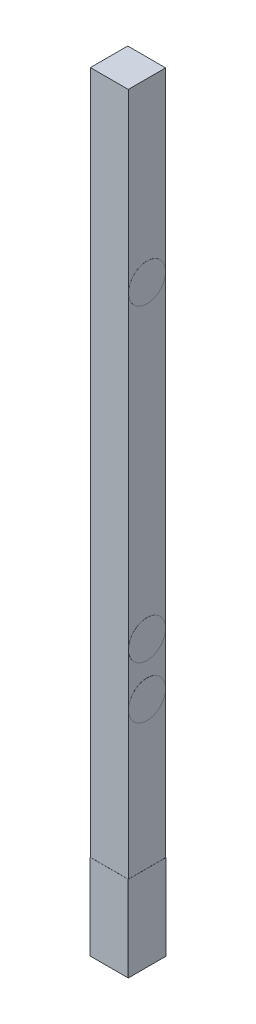
from build123d import *

# Parameters (mm, degrees)
SKETCH1_W           = 45.02
SKETCH1_H           = 44.376857142
BOSS_EXTRUDE1_DEPTH = 914.4
SKETCH2_R           = 22
BOSS_EXTRUDE2_DEPTH = 0.1
SKETCH3_W           = 44.376857142
SKETCH3_H           = 101.6
BOSS_EXTRUDE3_DEPTH = 0.1
SKETCH4_W           = 45.12
SKETCH4_H           = 101.6
BOSS_EXTRUDE4_DEPTH = 0.1
SKETCH5_W           = 44.476857142
SKETCH5_H           = 101.6
BOSS_EXTRUDE5_DEPTH = 0.1
SKETCH6_W           = 45.12
SKETCH6_H           = 101.6
BOSS_EXTRUDE6_DEPTH = 0.1


with BuildPart() as part:
    # Sketch1 → Boss-Extrude1 (new body)
    with BuildSketch(Plane(origin=(0, 0, 0), x_dir=(1, 0, 0), z_dir=(0, 1, 0))):
        Rectangle(SKETCH1_W, SKETCH1_H)
    extrude(amount=BOSS_EXTRUDE1_DEPTH)

    # Sketch2 → Boss-Extrude2 (add)
    with BuildSketch(Plane(origin=(22.51, 0, 0), x_dir=(0, 0, -1), z_dir=(1, 0, 0))):
        with Locations((0, 275.7)):
            Circle(SKETCH2_R)
        with Locations((0, 337.8)):
            Circle(SKETCH2_R)
        with Locations((0, 704.8)):
            Circle(SKETCH2_R)
    extrude(amount=BOSS_EXTRUDE2_DEPTH)

    # Sketch3 → Boss-Extrude3 (add)
    with BuildSketch(Plane(origin=(22.51, 0, 0), x_dir=(0, 0, -1), z_dir=(1, 0, 0))):
        with Locations((0, 50.8)):
            Rectangle(SKETCH3_W, SKETCH3_H)
    extrude(amount=BOSS_EXTRUDE3_DEPTH)

    # Sketch4 → Boss-Extrude4 (add)
    with BuildSketch(Plane(origin=(0, 0, -22.188428571), x_dir=(-1, 0, 0), z_dir=(0, 0, -1))):
        with Locations((-0.05, 50.8)):
            Rectangle(SKETCH4_W, SKETCH4_H)
    extrude(amount=BOSS_EXTRUDE4_DEPTH)

    # Sketch5 → Boss-Extrude5 (add)
    with BuildSketch(Plane.ZY.offset(22.51)):
        with Locations((-0.05, 50.8)):
            Rectangle(SKETCH5_W, SKETCH5_H)
    extrude(amount=BOSS_EXTRUDE5_DEPTH)

    # Sketch6 → Boss-Extrude6 (add)
    with BuildSketch(Plane.XY.offset(22.188428571)):
        with Locations((-0.05, 50.8)):
            Rectangle(SKETCH6_W, SKETCH6_H)
    extrude(amount=BOSS_EXTRUDE6_DEPTH)


solid = part.part
